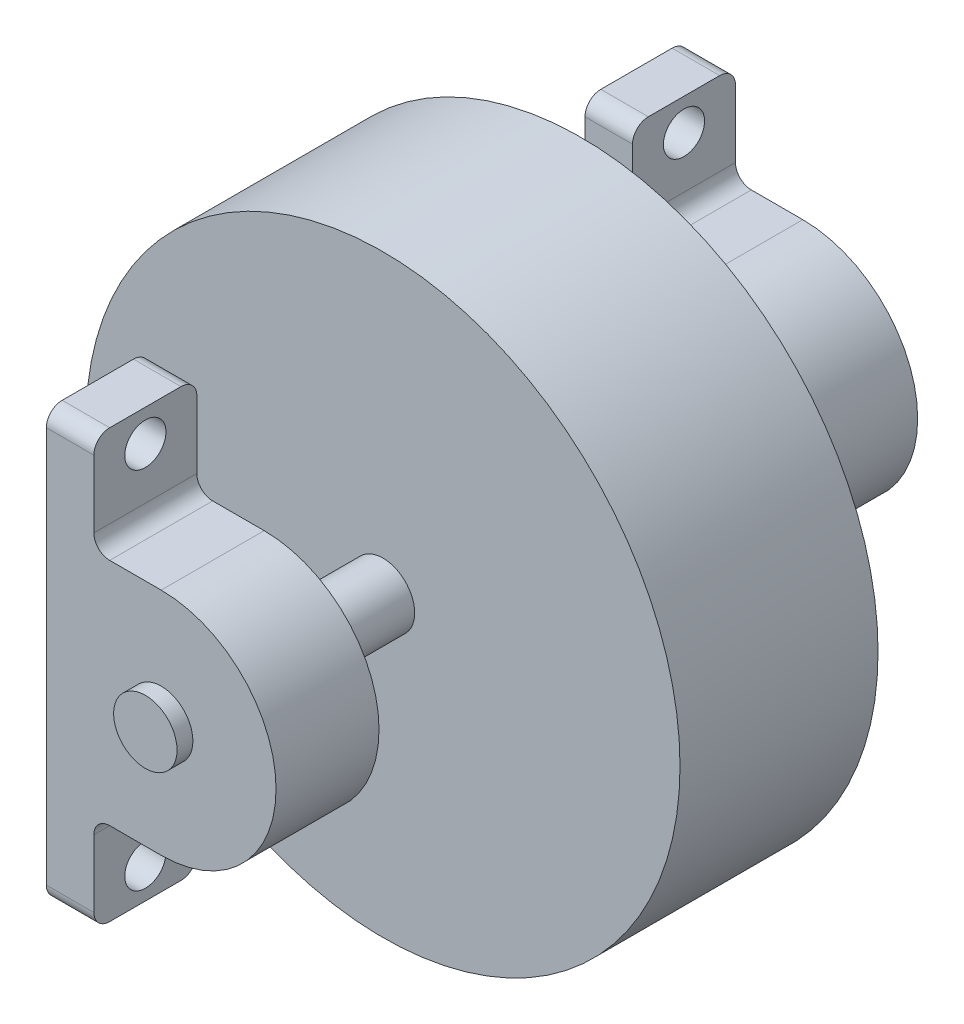
from build123d import *

# Parameters (mm, degrees)
EXTRUDE_1_DEPTH      = 12.5
EXTRUDE_1_DEPTH_BACK = 12.5
SKETCH_1_R           = 37.5
EXTRUDE_2_DEPTH      = 42.5
EXTRUDE_2_DEPTH_BACK = 42.5
SKETCH_1_3_R         = 4
EXTRUDE_3_DEPTH      = 13
EXTRUDE_START        = -13
EXTRUDE_4_DEPTH      = 13
SKETCH_4_R           = 2.6
CUT_EXTRUDE_1_DEPTH  = 73.996575262
FILLET_1_R           = 2


with BuildPart() as part:
    # 草图1 → 凸台-拉伸1 (new, two sides: drawn at the far end of the back side and taken through both)
    with BuildSketch(Plane.XY.offset(-EXTRUDE_1_DEPTH_BACK)):
        Circle(SKETCH_1_R)
    extrude(amount=EXTRUDE_1_DEPTH + EXTRUDE_1_DEPTH_BACK)

    # 草图1<3> → 凸台-拉伸2 (add, two sides: drawn at the far end of the back side and taken through both)
    with BuildSketch(Plane.XY.offset(-EXTRUDE_2_DEPTH_BACK)):
        Circle(SKETCH_1_3_R)
    extrude(amount=EXTRUDE_2_DEPTH + EXTRUDE_2_DEPTH_BACK)

    # 草图2 → 凸台-拉伸3 (add)
    with BuildSketch(Plane.XY.offset(40.5)):
        with BuildLine():
            Line((0, 14.5), (-8.5, 14.5))
            Line((-8.5, 14.5), (-8.5, 27))
            Line((-8.5, 27), (-14.5, 27))
            Line((-14.5, 27), (-14.5, -27))
            Line((-14.5, -27), (-8.5, -27))
            Line((-8.5, -27), (-8.5, -14.5))
            Line((-8.5, -14.5), (0, -14.5))
            ThreePointArc((0, -14.5), (14.5, 0), (0, 14.5))
        make_face()
    extrude(amount=-EXTRUDE_3_DEPTH)

    # 草图3 → 凸台-拉伸4 (add)
    with BuildSketch(Plane(origin=(0, 0, -40.5), x_dir=(-1, 0, 0), z_dir=(0, 0, -1)).offset(EXTRUDE_START)):
        with BuildLine():
            ThreePointArc((0, 14.5), (-14.5, 0), (0, -14.5))
            Line((0, -14.5), (8.5, -14.5))
            Line((8.5, -14.5), (8.5, -27))
            Line((8.5, -27), (14.5, -27))
            Line((14.5, -27), (14.5, 27))
            Line((14.5, 27), (8.5, 27))
            Line((8.5, 27), (8.5, 14.5))
            Line((8.5, 14.5), (0, 14.5))
        make_face()
    extrude(amount=EXTRUDE_4_DEPTH)

    # 草图4 → 切除-拉伸1 (cut, through all)
    with BuildSketch(Plane(origin=(-8.5, 0, 0), x_dir=(0, 0, -1), z_dir=(1, 0, 0))):
        with Locations((34, 23)):
            Circle(SKETCH_4_R)
        with Locations((34, -23)):
            Circle(SKETCH_4_R)
        with Locations((-34, -23)):
            Circle(SKETCH_4_R)
        with Locations((-34, 23)):
            Circle(SKETCH_4_R)
    extrude(amount=-CUT_EXTRUDE_1_DEPTH, mode=Mode.SUBTRACT)

    # 圆角1
    fillet_1_edges = [part.edges().sort_by_distance(p)[0] for p in [
        (-11.5, 27, 27.5),
        (-11.5, 27, 40.5),
        (-8.5, 14.5, 34),
        (-8.5, -14.5, 34),
        (-11.5, -27, 40.5),
        (-11.5, -27, 27.5),
        (-11.5, -27, -27.5),
        (-11.5, 27, -27.5),
        (-11.5, 27, -40.5),
        (-11.5, -27, -40.5),
        (-8.5, -14.5, -34),
        (-8.5, 14.5, -34),
    ]]
    fillet(fillet_1_edges, radius=FILLET_1_R)


solid = part.part
